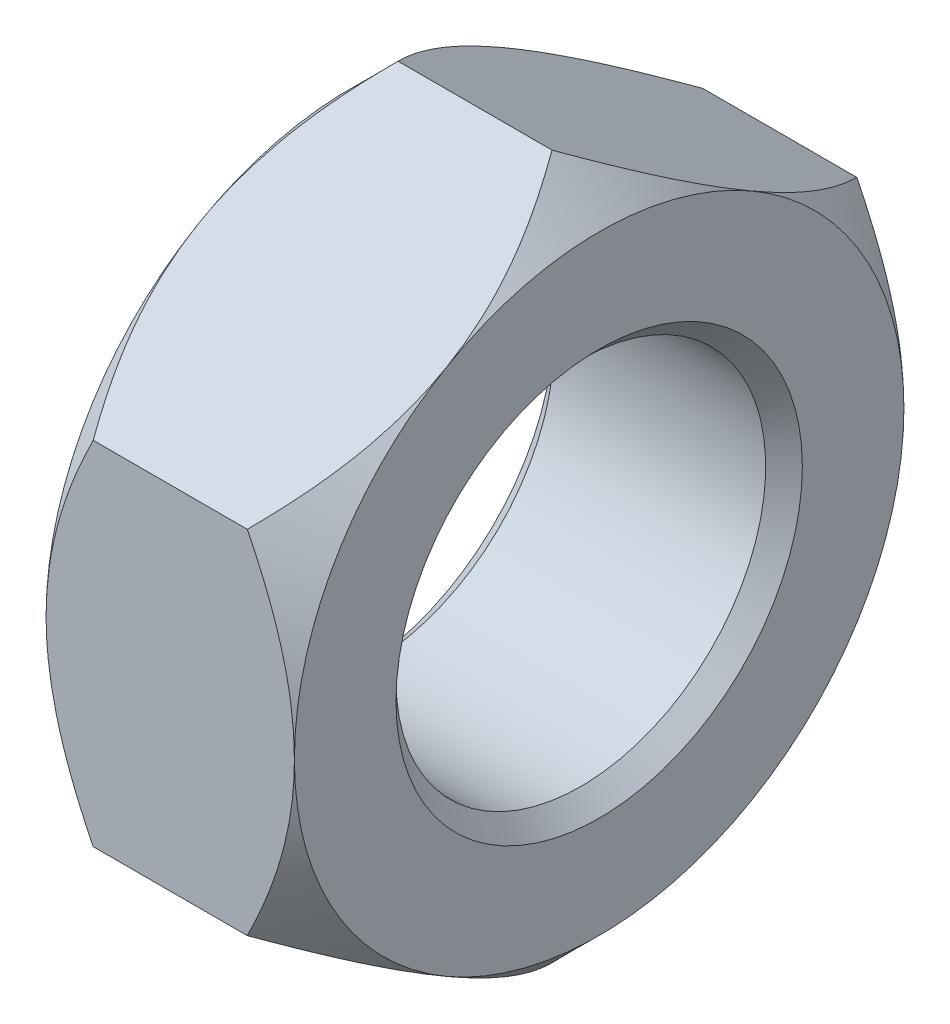
from build123d import *

# Parameters (mm, degrees)
CUT_EXTRUDE_1_DEPTH      = 54
CUT_EXTRUDE_1_DEPTH_BACK = 54
SKETCH_3_W               = 54
SKETCH_3_H               = 54


with BuildPart() as part:
    # 草图1 → 旋转1 (revolve)
    with BuildSketch(Plane.XY):
        Polygon((0, 0), (0, 13.5), (2.7, 16.2), (8.3, 16.2), (11, 13.5), (11, 0), align=None)
    revolve(axis=Axis((11, 0, 0), (-1, 0, 0)))

    # 草图2 → 切除-旋转1 (revolve, cut)
    with BuildSketch(Plane.XY):
        Polygon((0, 0), (0, 9), (0.812, 8.188), (10.188, 8.188), (11, 9), (11, 0), align=None)
    revolve(axis=Axis((11, 0, 0), (-1, 0, 0)), mode=Mode.SUBTRACT)

    # 草图3 → 切除-拉伸1 (cut, two sides: drawn at the far end of the back side and taken through both)
    with BuildSketch(Plane(origin=(0, 0, 0), x_dir=(0, 0, -1), z_dir=(1, 0, 0)).offset(-CUT_EXTRUDE_1_DEPTH_BACK)):
        Rectangle(SKETCH_3_W, SKETCH_3_H)
        Polygon((-13.5, -7.794228634), (0, -15.588457268), (13.5, -7.794228634), (13.5, 7.794228634), (0, 15.588457268), (-13.5, 7.794228634), align=None, mode=Mode.SUBTRACT)
    extrude(amount=CUT_EXTRUDE_1_DEPTH + CUT_EXTRUDE_1_DEPTH_BACK, mode=Mode.SUBTRACT)


solid = part.part
